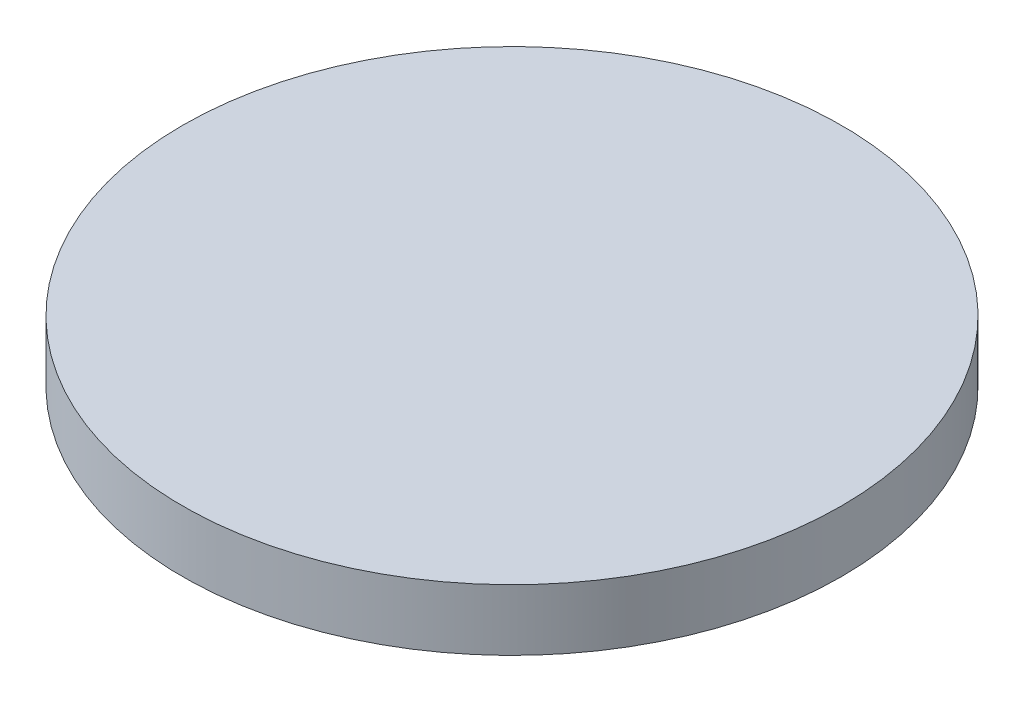
from build123d import *

# Parameters (mm, degrees)
SKETCH2_W = 34.163
SKETCH2_H = 6.35


with BuildPart() as part:
    # Sketch2 → Revolve2 (revolve)
    with BuildSketch(Plane.XY):
        with Locations((17.0815, -3.175)):
            Rectangle(SKETCH2_W, SKETCH2_H)
    revolve(axis=Axis((0, -815.84787415, 0), (0, -1, 0)))


solid = part.part
